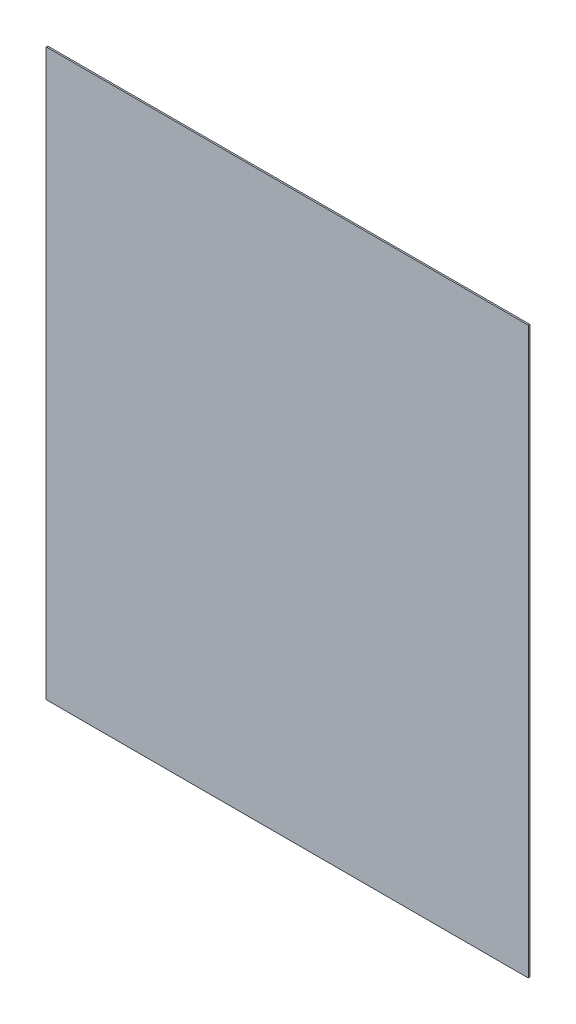
from build123d import *

# Parameters (mm, degrees)
SKETCH1_W           = 324
SKETCH1_H           = 380
BOSS_EXTRUDE1_DEPTH = 1


with BuildPart() as part:
    # Sketch1 → Boss-Extrude1 (new body)
    with BuildSketch(Plane.XY):
        with Locations((162, 190)):
            Rectangle(SKETCH1_W, SKETCH1_H)
    extrude(amount=BOSS_EXTRUDE1_DEPTH)


solid = part.part
